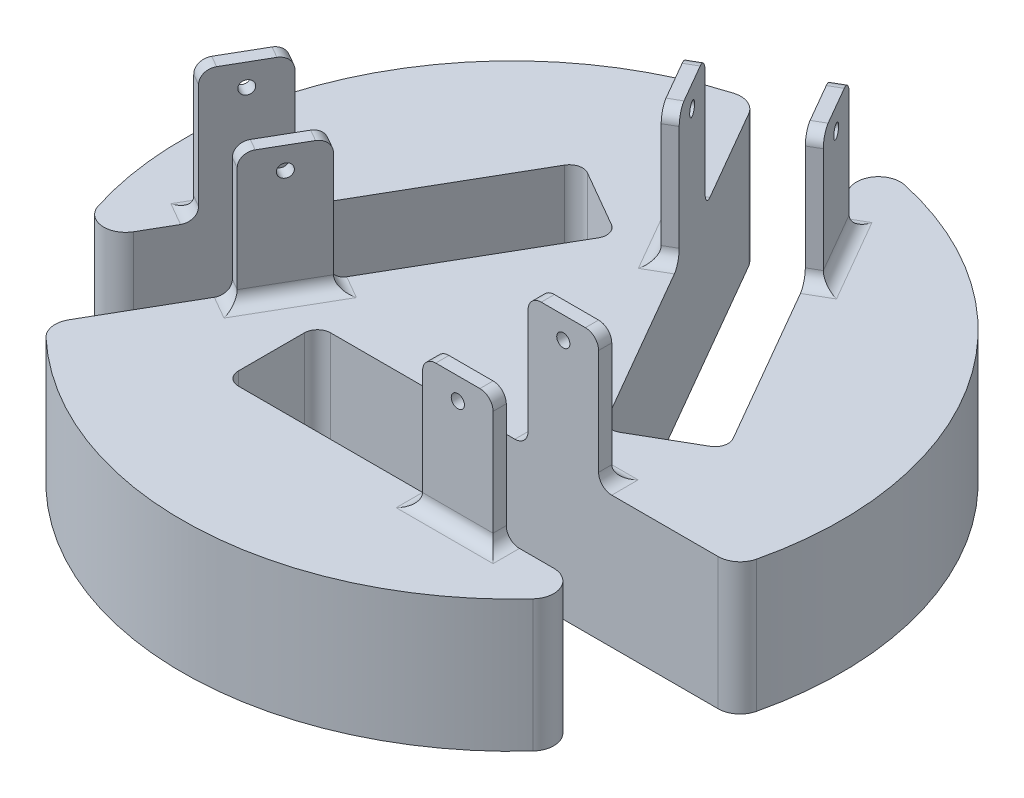
from build123d import *

# Parameters (mm, degrees)
SKETCH1_R                = 75
BOSS_EXTRUDE1_DEPTH      = 30
SKETCH2_W                = 16.050334996
SKETCH2_H                = 27
BOSS_EXTRUDE3_DEPTH      = 30
SKETCH3_R                = 1.5
CUT_EXTRUDE3_DEPTH       = 57.805954881
CUT_EXTRUDE3_DEPTH_BACK  = 94.194045119
SKETCH4_R                = 1.5
CUT_EXTRUDE4_DEPTH       = 148.645950403
SKETCH6_R                = 1.5
CUT_EXTRUDE5_DEPTH       = 148.645950403
SKETCH7_W                = 16.050693915
SKETCH7_H                = 21
CUT_EXTRUDE6_DEPTH       = 24
CUT_EXTRUDE7_DEPTH       = 24
CUT_EXTRUDE8_DEPTH       = 24
FILLET4_R                = 3
CUT_EXTRUDE9_DEPTH       = 25
CUT_EXTRUDE9_DEPTH_BACK  = 37
CUT_EXTRUDE10_DEPTH      = 25
CUT_EXTRUDE10_DEPTH_BACK = 37
SKETCH12_W               = 95
SKETCH12_H               = 21
CUT_EXTRUDE11_DEPTH      = 25
CUT_EXTRUDE11_DEPTH_BACK = 37
FILLET5_R                = 5
FILLET6_R                = 3
FILLET7_R                = 3


with BuildPart() as part:
    # Sketch1 → Boss-Extrude1 (new body)
    with BuildSketch(Plane(origin=(0, 0, 0), x_dir=(1, 0, 0), z_dir=(0, 1, 0))):
        Circle(SKETCH1_R)
    extrude(amount=BOSS_EXTRUDE1_DEPTH)

    # Sketch2 → Boss-Extrude3 (add)
    with BuildSketch(Plane(origin=(0, 30, 0), x_dir=(1, 0, 0), z_dir=(0, 1, 0))):
        Polygon((3.333824547, 30.61373674), (26.716510449, 44.11373674), (18.691342951, 58.013734586), (-4.691342951, 44.513734586), align=None)
        with Locations((32.870528946, -31.694045119)):
            Rectangle(SKETCH2_W, SKETCH2_H)
        Polygon((-59.587039395, -12.819689466), (-36.204353493, -26.319689466), (-28.179185995, -12.419691621), (-51.561871897, 1.080308379), align=None)
    extrude(amount=BOSS_EXTRUDE3_DEPTH)

    # Sketch3 → Cut-Extrude3 (cut, two sides)
    with BuildSketch(Plane(origin=(24.845361448, 30, 18.194045119), x_dir=(1, 0, 0), z_dir=(0, 0, 1))) as cut_extrude3_sk:
        with Locations((8.025167498, 25)):
            Circle(SKETCH3_R)
    extrude(amount=CUT_EXTRUDE3_DEPTH, mode=Mode.SUBTRACT)
    extrude(cut_extrude3_sk.sketch, amount=-CUT_EXTRUDE3_DEPTH_BACK, mode=Mode.SUBTRACT)

    # Sketch4 → Cut-Extrude4 (cut, through all)
    with BuildSketch(Plane(origin=(-39.139191173, 0, -22.59702256), x_dir=(-0.5, 0, 0.866025404), z_dir=(-0.866025404, 0, -0.5))):
        with Locations((32.870528946, 55)):
            Circle(SKETCH4_R)
    extrude(amount=-CUT_EXTRUDE4_DEPTH, mode=Mode.SUBTRACT)

    # Sketch6 → Cut-Extrude5 (cut, through all)
    with BuildSketch(Plane(origin=(39.139191173, 0, -22.59702256), x_dir=(-0.5, 0, -0.866025404), z_dir=(0.866025404, 0, -0.5))):
        with Locations((32.870528946, 55)):
            Circle(SKETCH6_R)
    extrude(amount=-CUT_EXTRUDE5_DEPTH, mode=Mode.SUBTRACT)

    # Sketch7 → Cut-Extrude6 (cut)
    with BuildSketch(Plane(origin=(0, 60, 0), x_dir=(1, 0, 0), z_dir=(0, 1, 0))):
        with Locations((32.870349487, -31.694045119)):
            Rectangle(SKETCH7_W, SKETCH7_H)
    extrude(amount=-CUT_EXTRUDE6_DEPTH, mode=Mode.SUBTRACT)

    # Sketch8 → Cut-Extrude7 (cut)
    with BuildSketch(Plane(origin=(0, 60, 0), x_dir=(1, 0, 0), z_dir=(0, 1, 0))):
        Polygon((-30.777262206, -10.919691621), (-48.963795686, -0.419691621), (-56.988963184, -14.319689466), (-38.802429704, -24.819689466), align=None)
    extrude(amount=-CUT_EXTRUDE7_DEPTH, mode=Mode.SUBTRACT)

    # Sketch9 → Cut-Extrude8 (cut)
    with BuildSketch(Plane(origin=(0, 60, 0), x_dir=(1, 0, 0), z_dir=(0, 1, 0))):
        Polygon((16.09326674, 56.513734586), (24.118434238, 42.61373674), (5.931900758, 32.11373674), (-2.09326674, 46.013734586), align=None)
    extrude(amount=-CUT_EXTRUDE8_DEPTH, mode=Mode.SUBTRACT)

    # Fillet4
    fillet4_edges = [part.edges().sort_by_distance(p)[0] for p in [
        (24.845361448, 30, 31.694045119),
        (32.870528946, 30, 45.194045119),
        (40.895696444, 30, 31.694045119),
        (32.870528946, 30, 18.194045119),
        (22.7039267, 30, -51.063735663),
        (7, 30, -51.263734586),
        (-0.678759202, 30, -37.563735663),
        (15.025167498, 30, -37.36373674),
        (-32.191769744, 30, 19.369690543),
        (-39.870528946, 30, 5.669691621),
        (-55.574455646, 30, 5.869690543),
        (-47.895696444, 30, 19.569689466),
    ]]
    fillet(fillet4_edges, radius=FILLET4_R)

    # Sketch10 → Cut-Extrude9 (cut, two sides)
    with BuildSketch(Plane(origin=(0, 36, 0), x_dir=(1, 0, 0), z_dir=(0, 1, 0))) as cut_extrude9_sk:
        Polygon((-25.01267474, 41.064866756), (-6.82614126, 30.564866756), (-54.32614126, -51.707546603), (-72.51267474, -41.207546603), align=None)
    extrude(amount=CUT_EXTRUDE9_DEPTH, mode=Mode.SUBTRACT)
    extrude(cut_extrude9_sk.sketch, amount=-CUT_EXTRUDE9_DEPTH_BACK, mode=Mode.SUBTRACT)

    # Sketch11 → Cut-Extrude10 (cut, two sides)
    with BuildSketch(Plane(origin=(0, 36, 0), x_dir=(1, 0, 0), z_dir=(0, 1, 0))) as cut_extrude10_sk:
        Polygon((-17.616978296, 72.901591723), (0.569555184, 83.401591723), (48.069555184, 1.129178363), (29.883021704, -9.370821637), align=None)
    extrude(amount=CUT_EXTRUDE10_DEPTH, mode=Mode.SUBTRACT)
    extrude(cut_extrude10_sk.sketch, amount=-CUT_EXTRUDE10_DEPTH_BACK, mode=Mode.SUBTRACT)

    # Sketch12 → Cut-Extrude11 (cut, two sides)
    with BuildSketch(Plane(origin=(0, 36, 0), x_dir=(1, 0, 0), z_dir=(0, 1, 0))) as cut_extrude11_sk:
        with Locations((24.443119556, -31.694045119)):
            Rectangle(SKETCH12_W, SKETCH12_H)
    extrude(amount=CUT_EXTRUDE11_DEPTH, mode=Mode.SUBTRACT)
    extrude(cut_extrude11_sk.sketch, amount=-CUT_EXTRUDE11_DEPTH_BACK, mode=Mode.SUBTRACT)

    # Fillet5
    fillet5_edges = [part.edges().sort_by_distance(p)[0] for p in [
        (-67.543786445, 15, 32.60117962),
        (-54.32614126, 15, 51.707546603),
        (5.538443478, 15, -74.79522474),
        (-17.616978296, 15, -72.901591723),
        (62.005342967, 15, 42.194045119),
        (71.943119556, 15, 21.194045119),
    ]]
    fillet(fillet5_edges, radius=FILLET5_R)

    # Fillet6
    fillet6_edges = [part.edges().sort_by_distance(p)[0] for p in [
        (-25.01267474, 15, -41.064866756),
        (-6.82614126, 15, -30.564866756),
        (29.883021704, 15, 9.370821637),
        (48.069555184, 15, -1.129178363),
        (-23.056880444, 15, 42.194045119),
        (-23.056880444, 15, 21.194045119),
    ]]
    fillet(fillet6_edges, radius=FILLET6_R)

    # Fillet7
    fillet7_edges = [part.edges().sort_by_distance(p)[0] for p in [
        (-3.392304845, 60, -45.263734586),
        (25.417472343, 60, -43.36373674),
        (24.845361448, 60, 19.694045119),
        (40.895696444, 60, 43.694045119),
        (17.392304845, 60, -57.263734586),
        (4.632862653, 60, -31.36373674),
        (24.845361448, 60, 43.694045119),
        (40.895696444, 60, 19.694045119),
        (-50.262833792, 60, -0.330308379),
        (-37.503391599, 60, 25.569689466),
        (-29.478224101, 60, 11.669691621),
        (-58.28800129, 60, 13.569689466),
    ]]
    fillet(fillet7_edges, radius=FILLET7_R)


solid = part.part
